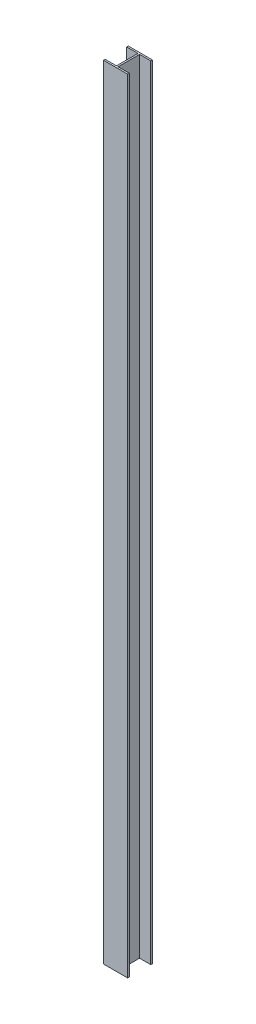
from build123d import *

# Parameters (mm, degrees)
BOSS_EXTRUDE1_DEPTH = 3352.8


with BuildPart() as part:
    # Sketch1 → Boss-Extrude1 (new body)
    with BuildSketch(Plane(origin=(0, 0, 0), x_dir=(1, 0, 0), z_dir=(0, 1, 0))):
        Polygon((-51.5, 70.861970597), (51.5, 70.861970597), (51.5, 63.761970597), (3.55, 63.761970597), (3.55, -28.038029403), (51.5, -28.038029403), (51.5, -35.138029403), (-51.5, -35.138029403), (-51.5, -28.038029403), (-3.55, -28.038029403), (-3.55, 63.761970597), (-51.5, 63.761970597), align=None)
    extrude(amount=BOSS_EXTRUDE1_DEPTH)


solid = part.part
